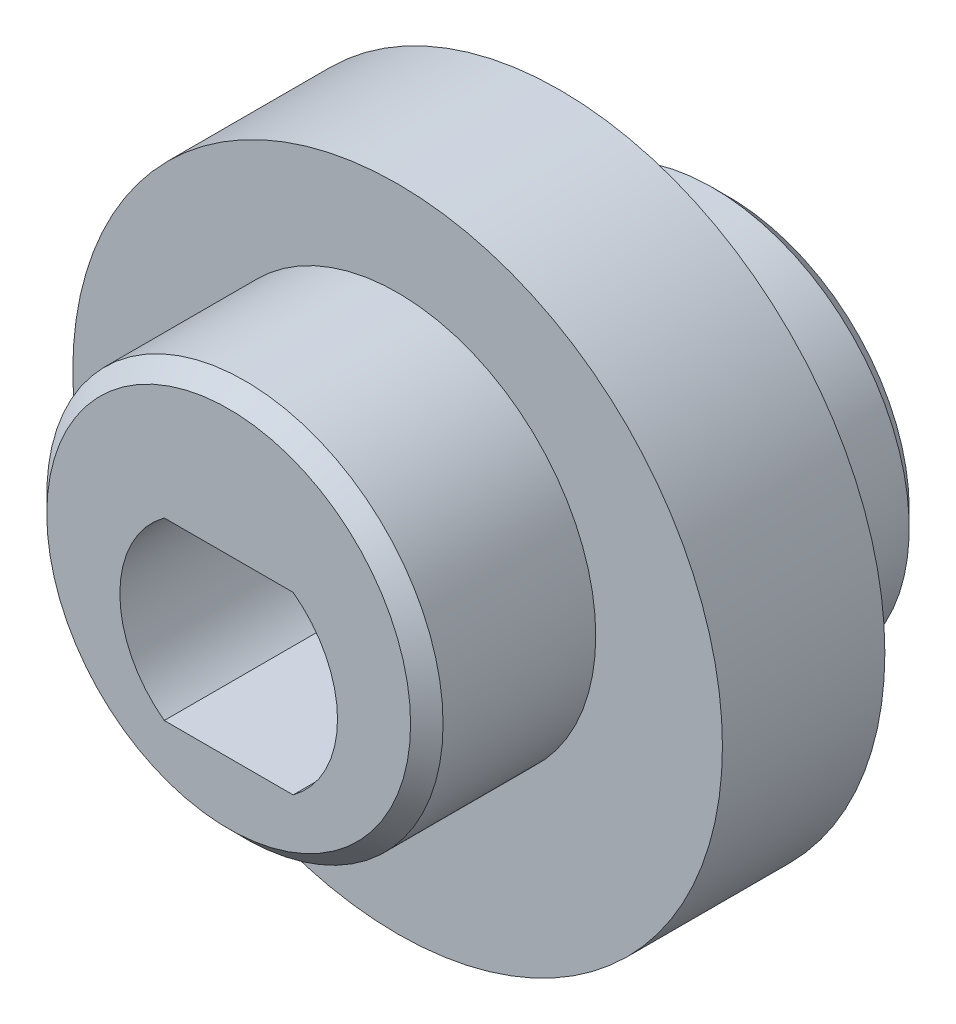
from build123d import *

# Parameters (mm, degrees)
SKETCH6_R               = 6
BOSS_EXTRUDE4_DEPTH     = 2.5
SKETCH7_R               = 6.1
BOSS_EXTRUDE5_DEPTH     = 5.2
SKETCH8_R               = 6.05
BOSS_EXTRUDE6_DEPTH     = 5.2
SKETCH13_R              = 10
BOSS_EXTRUDE7_DEPTH     = 5
CUT_EXTRUDE1_DEPTH      = 6.2
CUT_EXTRUDE1_DEPTH_BACK = 11.2
CHAMFER1_SIZE           = 0.5


with BuildPart() as part:
    # Sketch6 → Boss-Extrude4 (new body, symmetric)
    with BuildSketch(Plane.XY):
        Circle(SKETCH6_R)
    extrude(amount=BOSS_EXTRUDE4_DEPTH, both=True)

    # Sketch7 → Boss-Extrude5 (add)
    with BuildSketch(Plane.XY.offset(2.5)):
        with Locations((0, 1)):
            Circle(SKETCH7_R)
    extrude(amount=BOSS_EXTRUDE5_DEPTH)

    # Sketch8 → Boss-Extrude6 (add)
    with BuildSketch(Plane(origin=(0, 0, -2.5), x_dir=(-1, 0, 0), z_dir=(0, 0, -1))):
        with Locations((0, -1)):
            Circle(SKETCH8_R)
    extrude(amount=BOSS_EXTRUDE6_DEPTH)

    # Sketch13 → Boss-Extrude7 (add)
    with BuildSketch(Plane.XY.offset(2.5)):
        Circle(SKETCH13_R)
    extrude(amount=-BOSS_EXTRUDE7_DEPTH)

    # Sketch11 → Cut-Extrude1 (cut, two sides)
    with BuildSketch(Plane.XY.offset(2.5)) as cut_extrude1_sk:
        with BuildLine():
            Line((-1.983053202, -2.7), (1.983053202, -2.7))
            ThreePointArc((1.983053202, -2.7), (3.35, 0), (1.983053202, 2.7))
            Line((1.983053202, 2.7), (-1.983053202, 2.7))
            ThreePointArc((-1.983053202, 2.7), (-3.35, 0), (-1.983053202, -2.7))
        make_face()
    extrude(amount=CUT_EXTRUDE1_DEPTH, mode=Mode.SUBTRACT)
    extrude(cut_extrude1_sk.sketch, amount=-CUT_EXTRUDE1_DEPTH_BACK, mode=Mode.SUBTRACT)

    # Chamfer1
    chamfer1_edges = [part.edges().sort_by_distance(p)[0] for p in [
        (6.05, -1, -7.7),
        (-6.1, 1, 7.7),
    ]]
    chamfer(chamfer1_edges, length=CHAMFER1_SIZE)


solid = part.part
